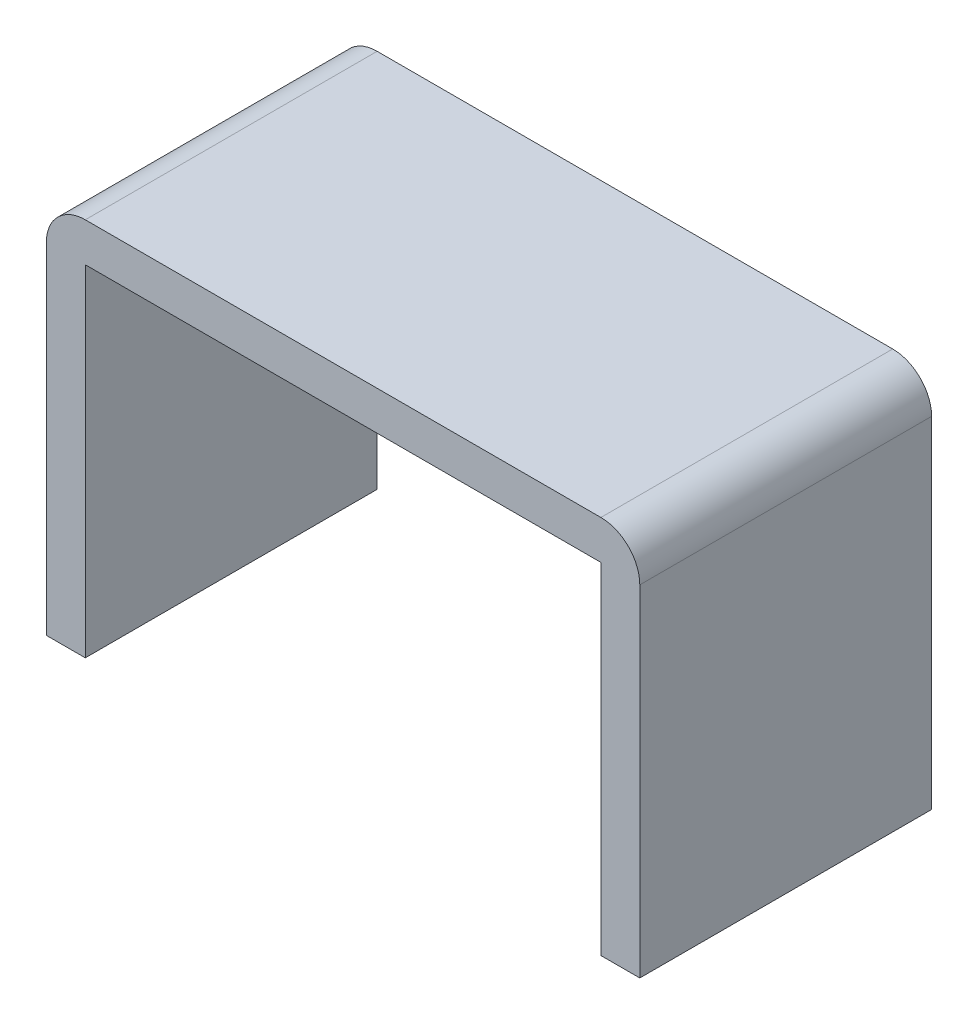
from build123d import *

# Parameters (mm, degrees)
BOSS_EXTRUDE1_DEPTH = 30


with BuildPart() as part:
    # Sketch1 → Boss-Extrude1 (new body)
    with BuildSketch(Plane.XY):
        with BuildLine():
            Line((0, 0), (0, 35))
            ThreePointArc((0, 35), (1.171572875, 37.828427125), (4, 39))
            Line((4, 39), (57, 39))
            ThreePointArc((57, 39), (59.828427125, 37.828427125), (61, 35))
            Line((61, 35), (61, 0))
            Line((61, 0), (57, 0))
            Line((57, 0), (57, 35))
            Line((57, 35), (4, 35))
            Line((4, 35), (4, 0))
            Line((4, 0), (0, 0))
        make_face()
    extrude(amount=BOSS_EXTRUDE1_DEPTH)


solid = part.part
